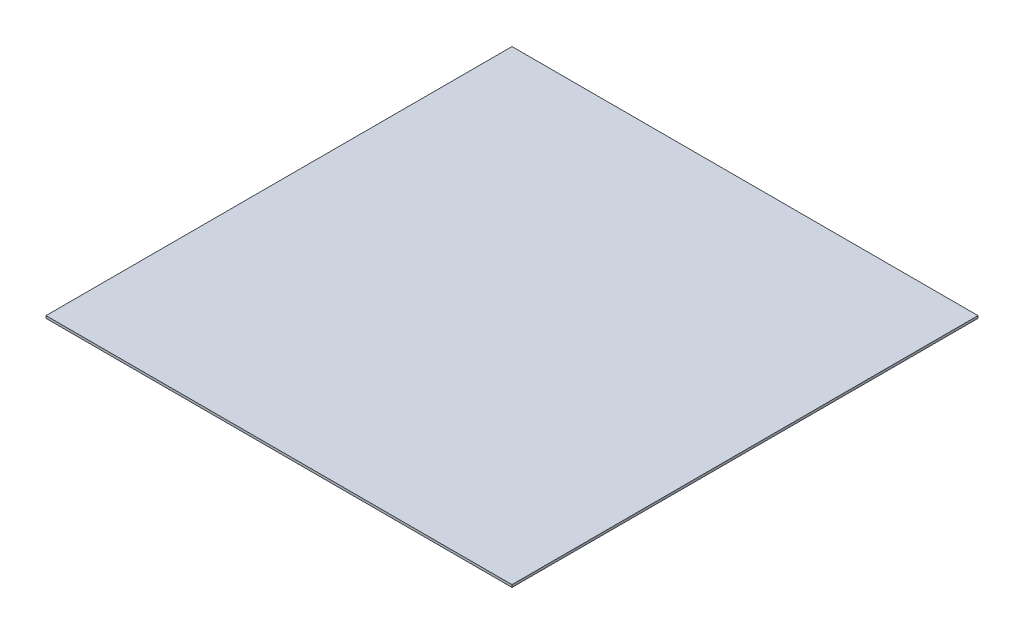
from build123d import *

# Parameters (mm, degrees)
SKETCH1_W           = 606.552
SKETCH1_H           = 606.552
BOSS_EXTRUDE1_DEPTH = 3.175


with BuildPart() as part:
    # Sketch1 → Boss-Extrude1 (new body)
    with BuildSketch(Plane(origin=(0, 0, 0), x_dir=(1, 0, 0), z_dir=(0, 1, 0))):
        Rectangle(SKETCH1_W, SKETCH1_H)
    extrude(amount=BOSS_EXTRUDE1_DEPTH)


solid = part.part
